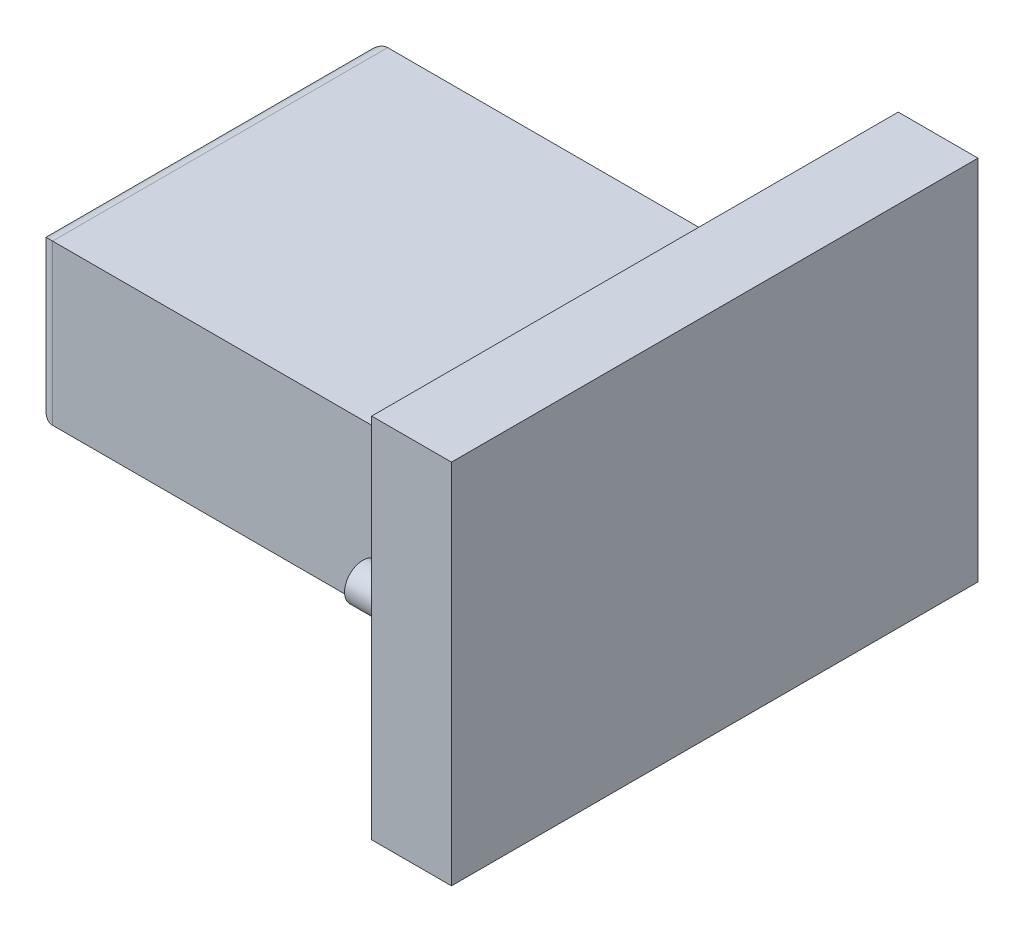
from build123d import *

# Parameters (mm, degrees)
SKETCH1_W           = 33
SKETCH1_H           = 23
BOSS_EXTRUDE1_DEPTH = 5
SKETCH2_W           = 21
SKETCH2_H           = 10
BOSS_EXTRUDE2_DEPTH = 27
FILLET1_R           = 1
SKETCH3_R           = 1.15
BOSS_EXTRUDE5_DEPTH = 2.8
FILLET9_R           = 0.25


with BuildPart() as part:
    # Sketch1 → Boss-Extrude1 (new body)
    with BuildSketch(Plane(origin=(0, 0, 0), x_dir=(0, 0, -1), z_dir=(1, 0, 0))):
        with Locations((16.5, 11.5)):
            Rectangle(SKETCH1_W, SKETCH1_H)
    extrude(amount=BOSS_EXTRUDE1_DEPTH)

    # Sketch2 → Boss-Extrude2 (add)
    with BuildSketch(Plane.ZY):
        with Locations((-16.5, 11.5)):
            Rectangle(SKETCH2_W, SKETCH2_H)
    extrude(amount=BOSS_EXTRUDE2_DEPTH)

    # Fillet1
    fillet1_edges = [part.edges().sort_by_distance(p)[0] for p in [
        (-27, 11.5, -27),
        (-27, 6.5, -16.5),
        (-27, 11.5, -6),
        (-27, 16.5, -16.5),
    ]]
    fillet(fillet1_edges, radius=FILLET1_R)

    # Sketch3 → Boss-Extrude5 (add)
    with BuildSketch(Plane.ZY):
        with Locations((-2.25, 11.5)):
            Circle(SKETCH3_R)
        with Locations((-30.75, 11.5)):
            Circle(SKETCH3_R)
    extrude(amount=BOSS_EXTRUDE5_DEPTH)

    # Fillet9
    fillet9_edges = [part.edges().sort_by_distance(p)[0] for p in [
        (0, 11.5, -3.4),
        (0, 11.5, -31.9),
    ]]
    fillet(fillet9_edges, radius=FILLET9_R)


solid = part.part
